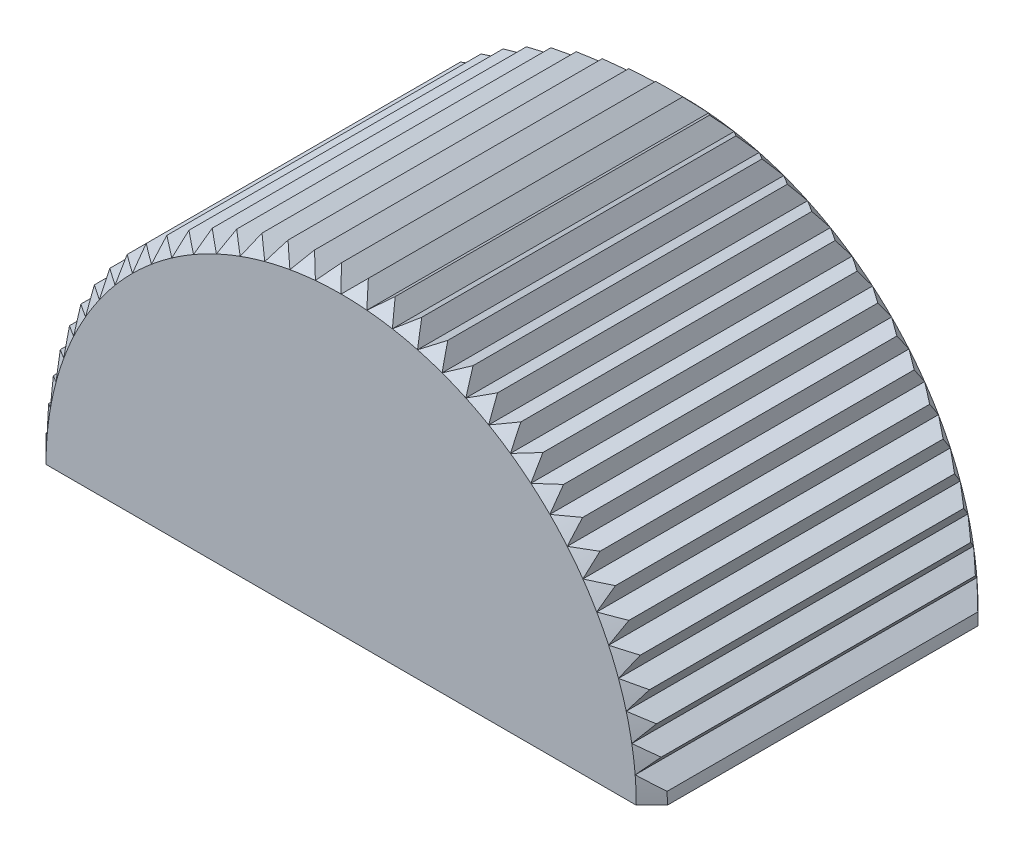
from build123d import *

# Parameters (mm, degrees)
BOSS_EXTRUDE1_DEPTH   = 5.5
CHAMFER1_SIZE         = 0.25
CUT_EXTRUDE1_DEPTH    = 6.5
CIRPATTERN1_COUNT     = 18
CIRPATTERN1_ANGLE     = 85
MIRROR1_COPY_1_DEPTH  = 6.5
MIRROR1_COPY_2_DEPTH  = 6.5
MIRROR1_COPY_3_DEPTH  = 6.5
MIRROR1_COPY_4_DEPTH  = 6.5
MIRROR1_COPY_5_DEPTH  = 6.5
MIRROR1_COPY_6_DEPTH  = 6.5
MIRROR1_COPY_7_DEPTH  = 6.5
MIRROR1_COPY_8_DEPTH  = 6.5
MIRROR1_COPY_9_DEPTH  = 6.5
MIRROR1_COPY_10_DEPTH = 6.5
MIRROR1_COPY_11_DEPTH = 6.5
MIRROR1_COPY_12_DEPTH = 6.5
MIRROR1_COPY_13_DEPTH = 6.5
MIRROR1_COPY_14_DEPTH = 6.5
MIRROR1_COPY_15_DEPTH = 6.5
MIRROR1_COPY_16_DEPTH = 6.5
MIRROR1_COPY_17_DEPTH = 6.5
MIRROR1_COPY_18_DEPTH = 6.5


with BuildPart() as part:
    # Sketch1 → Boss-Extrude1 (new body)
    with BuildSketch(Plane.XY):
        with BuildLine():
            Line((-5, 0), (5, 0))
            ThreePointArc((5, 0), (0, 5), (-5, 0))
        make_face()
    extrude(amount=BOSS_EXTRUDE1_DEPTH)

    # Chamfer1
    chamfer1_edges = [part.edges().sort_by_distance(p)[0] for p in [
        (0, 5, 0),
        (0, 5, 5.5),
    ]]
    chamfer(chamfer1_edges, length=CHAMFER1_SIZE)

    # Sketch2 → Cut-Extrude1 (cut, through all)
    with BuildSketch(Plane.XY.offset(5.5)):
        with BuildLine():
            Line((0, 4.75), (0.244040855, 4.994040855))
            ThreePointArc((0.244040855, 4.994040855), (0, 5), (-0.244040855, 4.994040855))
            Line((-0.244040855, 4.994040855), (0, 4.75))
        make_face()
    cut_extrude1 = extrude(amount=-CUT_EXTRUDE1_DEPTH, mode=Mode.SUBTRACT)

    # CirPattern1: Cut-Extrude1 ×18 about axis
    cirpattern1_axis = Axis((0, 0, 0), (0, 0, 1))
    for i in range(1, CIRPATTERN1_COUNT):
        add(cut_extrude1.rotate(cirpattern1_axis, i * CIRPATTERN1_ANGLE / (CIRPATTERN1_COUNT - 1)), mode=Mode.SUBTRACT)

    # Mirror1 copy 1 sketch → Mirror1 copy 1 (cut, through all)
    with BuildSketch(Plane(origin=(0, 0, 5.5), x_dir=(-0.996194698, 0.087155743, 0), z_dir=(0, 0, 1))):
        with BuildLine():
            Line((0, -4.75), (0.244040855, -4.994040855))
            ThreePointArc((0.244040855, -4.994040855), (0, -5), (-0.244040855, -4.994040855))
            Line((-0.244040855, -4.994040855), (0, -4.75))
        make_face()
    extrude(amount=-MIRROR1_COPY_1_DEPTH, mode=Mode.SUBTRACT)

    # Mirror1 copy 2 sketch → Mirror1 copy 2 (cut, through all)
    with BuildSketch(Plane(origin=(0, 0, 5.5), x_dir=(-0.984807753, 0.173648178, 0), z_dir=(0, 0, 1))):
        with BuildLine():
            Line((0, -4.75), (0.244040855, -4.994040855))
            ThreePointArc((0.244040855, -4.994040855), (0, -5), (-0.244040855, -4.994040855))
            Line((-0.244040855, -4.994040855), (0, -4.75))
        make_face()
    extrude(amount=-MIRROR1_COPY_2_DEPTH, mode=Mode.SUBTRACT)

    # Mirror1 copy 3 sketch → Mirror1 copy 3 (cut, through all)
    with BuildSketch(Plane(origin=(0, 0, 5.5), x_dir=(-0.965925826, 0.258819045, 0), z_dir=(0, 0, 1))):
        with BuildLine():
            Line((0, -4.75), (0.244040855, -4.994040855))
            ThreePointArc((0.244040855, -4.994040855), (0, -5), (-0.244040855, -4.994040855))
            Line((-0.244040855, -4.994040855), (0, -4.75))
        make_face()
    extrude(amount=-MIRROR1_COPY_3_DEPTH, mode=Mode.SUBTRACT)

    # Mirror1 copy 4 sketch → Mirror1 copy 4 (cut, through all)
    with BuildSketch(Plane(origin=(0, 0, 5.5), x_dir=(-0.939692621, 0.342020143, 0), z_dir=(0, 0, 1))):
        with BuildLine():
            Line((0, -4.75), (0.244040855, -4.994040855))
            ThreePointArc((0.244040855, -4.994040855), (0, -5), (-0.244040855, -4.994040855))
            Line((-0.244040855, -4.994040855), (0, -4.75))
        make_face()
    extrude(amount=-MIRROR1_COPY_4_DEPTH, mode=Mode.SUBTRACT)

    # Mirror1 copy 5 sketch → Mirror1 copy 5 (cut, through all)
    with BuildSketch(Plane(origin=(0, 0, 5.5), x_dir=(-0.906307787, 0.422618262, 0), z_dir=(0, 0, 1))):
        with BuildLine():
            Line((0, -4.75), (0.244040855, -4.994040855))
            ThreePointArc((0.244040855, -4.994040855), (0, -5), (-0.244040855, -4.994040855))
            Line((-0.244040855, -4.994040855), (0, -4.75))
        make_face()
    extrude(amount=-MIRROR1_COPY_5_DEPTH, mode=Mode.SUBTRACT)

    # Mirror1 copy 6 sketch → Mirror1 copy 6 (cut, through all)
    with BuildSketch(Plane(origin=(0, 0, 5.5), x_dir=(-0.866025404, 0.5, 0), z_dir=(0, 0, 1))):
        with BuildLine():
            Line((0, -4.75), (0.244040855, -4.994040855))
            ThreePointArc((0.244040855, -4.994040855), (0, -5), (-0.244040855, -4.994040855))
            Line((-0.244040855, -4.994040855), (0, -4.75))
        make_face()
    extrude(amount=-MIRROR1_COPY_6_DEPTH, mode=Mode.SUBTRACT)

    # Mirror1 copy 7 sketch → Mirror1 copy 7 (cut, through all)
    with BuildSketch(Plane(origin=(0, 0, 5.5), x_dir=(-0.819152044, 0.573576436, 0), z_dir=(0, 0, 1))):
        with BuildLine():
            Line((0, -4.75), (0.244040855, -4.994040855))
            ThreePointArc((0.244040855, -4.994040855), (0, -5), (-0.244040855, -4.994040855))
            Line((-0.244040855, -4.994040855), (0, -4.75))
        make_face()
    extrude(amount=-MIRROR1_COPY_7_DEPTH, mode=Mode.SUBTRACT)

    # Mirror1 copy 8 sketch → Mirror1 copy 8 (cut, through all)
    with BuildSketch(Plane(origin=(0, 0, 5.5), x_dir=(-0.766044443, 0.64278761, 0), z_dir=(0, 0, 1))):
        with BuildLine():
            Line((0, -4.75), (0.244040855, -4.994040855))
            ThreePointArc((0.244040855, -4.994040855), (0, -5), (-0.244040855, -4.994040855))
            Line((-0.244040855, -4.994040855), (0, -4.75))
        make_face()
    extrude(amount=-MIRROR1_COPY_8_DEPTH, mode=Mode.SUBTRACT)

    # Mirror1 copy 9 sketch → Mirror1 copy 9 (cut, through all)
    with BuildSketch(Plane(origin=(0, 0, 5.5), x_dir=(-0.707106781, 0.707106781, 0), z_dir=(0, 0, 1))):
        with BuildLine():
            Line((0, -4.75), (0.244040855, -4.994040855))
            ThreePointArc((0.244040855, -4.994040855), (0, -5), (-0.244040855, -4.994040855))
            Line((-0.244040855, -4.994040855), (0, -4.75))
        make_face()
    extrude(amount=-MIRROR1_COPY_9_DEPTH, mode=Mode.SUBTRACT)

    # Mirror1 copy 10 sketch → Mirror1 copy 10 (cut, through all)
    with BuildSketch(Plane(origin=(0, 0, 5.5), x_dir=(-0.64278761, 0.766044443, 0), z_dir=(0, 0, 1))):
        with BuildLine():
            Line((0, -4.75), (0.244040855, -4.994040855))
            ThreePointArc((0.244040855, -4.994040855), (0, -5), (-0.244040855, -4.994040855))
            Line((-0.244040855, -4.994040855), (0, -4.75))
        make_face()
    extrude(amount=-MIRROR1_COPY_10_DEPTH, mode=Mode.SUBTRACT)

    # Mirror1 copy 11 sketch → Mirror1 copy 11 (cut, through all)
    with BuildSketch(Plane(origin=(0, 0, 5.5), x_dir=(-0.573576436, 0.819152044, 0), z_dir=(0, 0, 1))):
        with BuildLine():
            Line((0, -4.75), (0.244040855, -4.994040855))
            ThreePointArc((0.244040855, -4.994040855), (0, -5), (-0.244040855, -4.994040855))
            Line((-0.244040855, -4.994040855), (0, -4.75))
        make_face()
    extrude(amount=-MIRROR1_COPY_11_DEPTH, mode=Mode.SUBTRACT)

    # Mirror1 copy 12 sketch → Mirror1 copy 12 (cut, through all)
    with BuildSketch(Plane(origin=(0, 0, 5.5), x_dir=(-0.5, 0.866025404, 0), z_dir=(0, 0, 1))):
        with BuildLine():
            Line((0, -4.75), (0.244040855, -4.994040855))
            ThreePointArc((0.244040855, -4.994040855), (0, -5), (-0.244040855, -4.994040855))
            Line((-0.244040855, -4.994040855), (0, -4.75))
        make_face()
    extrude(amount=-MIRROR1_COPY_12_DEPTH, mode=Mode.SUBTRACT)

    # Mirror1 copy 13 sketch → Mirror1 copy 13 (cut, through all)
    with BuildSketch(Plane(origin=(0, 0, 5.5), x_dir=(-0.422618262, 0.906307787, 0), z_dir=(0, 0, 1))):
        with BuildLine():
            Line((0, -4.75), (0.244040855, -4.994040855))
            ThreePointArc((0.244040855, -4.994040855), (0, -5), (-0.244040855, -4.994040855))
            Line((-0.244040855, -4.994040855), (0, -4.75))
        make_face()
    extrude(amount=-MIRROR1_COPY_13_DEPTH, mode=Mode.SUBTRACT)

    # Mirror1 copy 14 sketch → Mirror1 copy 14 (cut, through all)
    with BuildSketch(Plane(origin=(0, 0, 5.5), x_dir=(-0.342020143, 0.939692621, 0), z_dir=(0, 0, 1))):
        with BuildLine():
            Line((0, -4.75), (0.244040855, -4.994040855))
            ThreePointArc((0.244040855, -4.994040855), (0, -5), (-0.244040855, -4.994040855))
            Line((-0.244040855, -4.994040855), (0, -4.75))
        make_face()
    extrude(amount=-MIRROR1_COPY_14_DEPTH, mode=Mode.SUBTRACT)

    # Mirror1 copy 15 sketch → Mirror1 copy 15 (cut, through all)
    with BuildSketch(Plane(origin=(0, 0, 5.5), x_dir=(-0.258819045, 0.965925826, 0), z_dir=(0, 0, 1))):
        with BuildLine():
            Line((0, -4.75), (0.244040855, -4.994040855))
            ThreePointArc((0.244040855, -4.994040855), (0, -5), (-0.244040855, -4.994040855))
            Line((-0.244040855, -4.994040855), (0, -4.75))
        make_face()
    extrude(amount=-MIRROR1_COPY_15_DEPTH, mode=Mode.SUBTRACT)

    # Mirror1 copy 16 sketch → Mirror1 copy 16 (cut, through all)
    with BuildSketch(Plane(origin=(0, 0, 5.5), x_dir=(-0.173648178, 0.984807753, 0), z_dir=(0, 0, 1))):
        with BuildLine():
            Line((0, -4.75), (0.244040855, -4.994040855))
            ThreePointArc((0.244040855, -4.994040855), (0, -5), (-0.244040855, -4.994040855))
            Line((-0.244040855, -4.994040855), (0, -4.75))
        make_face()
    extrude(amount=-MIRROR1_COPY_16_DEPTH, mode=Mode.SUBTRACT)

    # Mirror1 copy 17 sketch → Mirror1 copy 17 (cut, through all)
    with BuildSketch(Plane(origin=(0, 0, 5.5), x_dir=(-0.087155743, 0.996194698, 0), z_dir=(0, 0, 1))):
        with BuildLine():
            Line((0, -4.75), (0.244040855, -4.994040855))
            ThreePointArc((0.244040855, -4.994040855), (0, -5), (-0.244040855, -4.994040855))
            Line((-0.244040855, -4.994040855), (0, -4.75))
        make_face()
    extrude(amount=-MIRROR1_COPY_17_DEPTH, mode=Mode.SUBTRACT)

    # Mirror1 copy 18 sketch → Mirror1 copy 18 (cut, through all)
    with BuildSketch(Plane(origin=(0, 0, 5.5), x_dir=(-1, 0, 0), z_dir=(0, 0, 1))):
        with BuildLine():
            Line((0, -4.75), (0.244040855, -4.994040855))
            ThreePointArc((0.244040855, -4.994040855), (0, -5), (-0.244040855, -4.994040855))
            Line((-0.244040855, -4.994040855), (0, -4.75))
        make_face()
    extrude(amount=-MIRROR1_COPY_18_DEPTH, mode=Mode.SUBTRACT)


solid = part.part
